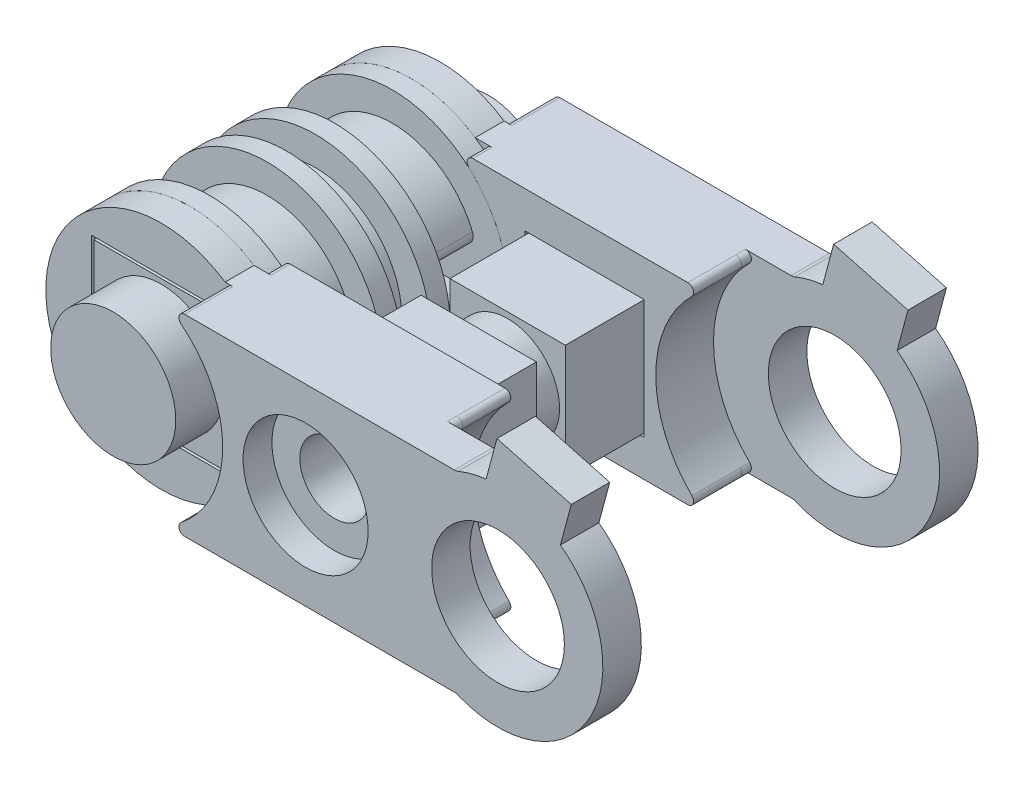
from build123d import *

# Parameters (mm, degrees)
SKETCH_1_R               = 4.5
EXTRUDE_1_DEPTH          = 3
SKETCH_2_R               = 6
EXTRUDE_2_DEPTH          = 1
EXTRUDE_START            = 1.5
SKETCH_3_R               = 4.5
EXTRUDE_3_DEPTH          = 1.5
SKETCH_4_R               = 6.000000000000001
EXTRUDE_4_DEPTH          = 1
EXTRUDE_START_2          = 3
SKETCH_5_R               = 4.5
EXTRUDE_5_DEPTH          = 3
SKETCH_6_R               = 6.000000000000001
EXTRUDE_6_DEPTH          = 1
EXTRUDE_START_3          = 1
SKETCH_7_R               = 6.000000000000001
EXTRUDE_7_DEPTH          = 1
EXTRUDE_10_DEPTH         = 1.5
SKETCH_11_R              = 3.25
EXTRUDE_11_DEPTH         = 2.5
EXTRUDE_12_DEPTH         = 1.5
EXTRUDE_13_DEPTH         = 0.5
FILLET_9_R               = 0.3
SKETCH_14_R              = 3.450000000000003
EXTRUDE_14_DEPTH         = 2
EXTRUDE_15_DEPTH         = 1
SKETCH_16_R              = 1.799999999999999
CUT_EXTRUDE_1_DEPTH      = 33.61828474950821
CUT_EXTRUDE_2_DEPTH      = 2
EXTRUDE_16_DEPTH         = 11.5
SKETCH_19_R              = 1.799999999999999
CUT_EXTRUDE_3_DEPTH      = 30.89903844607716
CUT_EXTRUDE_4_DEPTH      = 0.75
CUT_EXTRUDE_4_DEPTH_BACK = 0.75
SKETCH_20_R              = 2.6999999999999993
SKETCH_21_R              = 3.2500000000000027
CUT_EXTRUDE_5_DEPTH      = 1.5
CUT_EXTRUDE_6_DEPTH      = 1
EXTRUDE_17_DEPTH         = 2
EXTRUDE_18_DEPTH         = 2
SKETCH_25_W              = 3.0000000000000013
SKETCH_25_H              = 2
SKETCH_25_W_2            = 3
CUT_EXTRUDE_7_DEPTH      = 33.95166049436114
FILLET_10_R              = 0.5


with BuildPart() as part:
    # ｽｹｯﾁ1 → ﾎﾞｽ - 押し出し1 (new body)
    with BuildSketch(Plane.XY):
        Circle(SKETCH_1_R)
    extrude(amount=EXTRUDE_1_DEPTH)

    # ｽｹｯﾁ2 → ﾎﾞｽ - 押し出し2 (add)
    with BuildSketch(Plane(origin=(0, 0, 0), x_dir=(-1, 0, 0), z_dir=(0, 0, -1))):
        Circle(SKETCH_2_R)
    extrude(amount=EXTRUDE_2_DEPTH)

    # ｽｹｯﾁ3 → ﾎﾞｽ - 押し出し3 (add)
    with BuildSketch(Plane(origin=(0, 0, -1), x_dir=(-1, 0, 0), z_dir=(0, 0, -1)).offset(EXTRUDE_START)):
        with Locations(Location((0, 0, 0), (0, 0, 180))):
            Circle(SKETCH_3_R)
    extrude(amount=-EXTRUDE_3_DEPTH)

    # ｽｹｯﾁ4 → ﾎﾞｽ - 押し出し4 (add)
    with BuildSketch(Plane(origin=(0, 0, -2.5), x_dir=(-1, 0, 0), z_dir=(0, 0, -1))):
        Circle(SKETCH_4_R)
    extrude(amount=EXTRUDE_4_DEPTH)

    # ｽｹｯﾁ5 → ﾎﾞｽ - 押し出し5 (add)
    with BuildSketch(Plane(origin=(0, 0, -3.5), x_dir=(-1, 0, 0), z_dir=(0, 0, -1)).offset(EXTRUDE_START_2)):
        with Locations(Location((0, 0, 0), (0, 0, 180))):
            Circle(SKETCH_5_R)
    extrude(amount=-EXTRUDE_5_DEPTH)

    # ｽｹｯﾁ6 → ﾎﾞｽ - 押し出し6 (add)
    with BuildSketch(Plane(origin=(0, 0, -6.500000000000001), x_dir=(-1, 0, 0), z_dir=(0, 0, -1))):
        Circle(SKETCH_6_R)
    extrude(amount=EXTRUDE_6_DEPTH)

    # ｽｹｯﾁ7 → ﾎﾞｽ - 押し出し7 (add)
    with BuildSketch(Plane.XY.offset(3).offset(EXTRUDE_START_3)):
        with Locations(Location((0, 0, 0), (0, 0, 180))):
            Circle(SKETCH_7_R)
    extrude(amount=-EXTRUDE_7_DEPTH)

    # ｽｹｯﾁ10 → ﾎﾞｽ - 押し出し10 (add)
    with BuildSketch(Plane.XY.offset(4)):
        Polygon((3.4999999999999996, -3.5), (-3.5000000000000004, -3.500000000000001), (-3.5000000000000004, 3.5000000000000004), (3.4999999999999996, 3.5), align=None)
    extrude_10 = extrude(amount=EXTRUDE_10_DEPTH)

    # ｽｹｯﾁ11 → ﾎﾞｽ - 押し出し11 (add)
    with BuildSketch(Plane.XY.offset(5.5)):
        Circle(SKETCH_11_R)
    extrude_11 = extrude(amount=EXTRUDE_11_DEPTH)

    # ﾐﾗｰ1: ﾎﾞｽ - 押し出し10, ﾎﾞｽ - 押し出し11 across plane
    add(extrude_10.mirror(Plane.XY.offset(-1.7500000000000002)))
    add(extrude_11.mirror(Plane.XY.offset(-1.7500000000000002)))

    # ｽｹｯﾁ25 → ｶｯﾄ - 押し出し7 (cut, through all)
    with BuildSketch(Plane.ZY.offset(4.5)):
        with Locations((-5.000000000000001, 0)):
            Rectangle(SKETCH_25_W, SKETCH_25_H)
        with Locations((1.5, 0)):
            Rectangle(SKETCH_25_W_2, SKETCH_25_H)
    extrude(amount=-CUT_EXTRUDE_7_DEPTH, mode=Mode.SUBTRACT)

    # ﾌｨﾚｯﾄ10
    fillet_10_edges = [part.edges().sort_by_distance(p)[0] for p in [
        (-4.387482193696061, 1, -5),
        (4.387482193696061, 1, -5),
        (4.387482193696061, -1, -5),
        (-4.387482193696061, -1, -5),
        (4.387482193696061, 1, 1.5),
        (-4.387482193696061, 1, 1.5),
        (-4.387482193696061, -1, 1.5),
        (4.387482193696061, -1, 1.5),
    ]]
    fillet(fillet_10_edges, radius=FILLET_10_R)


with BuildPart() as body_2:
    # ｽｹｯﾁ12 → ﾎﾞｽ - 押し出し12 (new body)
    with BuildSketch(Plane.XY.offset(4)):
        with BuildLine():
            Line((3.3166247903554016, 5), (16.167246420652642, 5))
            ThreePointArc((16.167246420652642, 5), (13.700000000000001, 3.57e-15), (16.16724642065264, -5))
            Line((16.16724642065264, -5), (3.3166247903553985, -5.000000000000003))
            ThreePointArc((3.3166247903553985, -5.000000000000003), (-6.000000000000001, 7.3e-16), (3.3166247903554016, 5))
        make_face()
        Polygon((3.6399999999999997, -3.64), (3.6399999999999997, 3.64), (-3.6400000000000006, 3.6400000000000006), (-3.6400000000000006, -3.640000000000001), align=None, mode=Mode.SUBTRACT)
    extrude(amount=EXTRUDE_12_DEPTH)

    # ｽｹｯﾁ13 → ﾎﾞｽ - 押し出し13 (add)
    with BuildSketch(Plane.XY.offset(5.5)):
        with BuildLine():
            Line((15.366426864718767, 5.000000000000001), (3.71350238992787, 4.999999999999999))
            ThreePointArc((3.71350238992787, 4.999999999999999), (3.4301142319534543, 4.798443648448575), (3.5275172952737197, 4.464607679465777))
            ThreePointArc((3.5275172952737197, 4.464607679465777), (5.69, 3.16e-15), (3.527517295273725, -4.464607679465773))
            ThreePointArc((3.527517295273725, -4.464607679465773), (3.4301142319534588, -4.798443648448569), (3.713502389927875, -4.9999999999999964))
            Line((3.713502389927875, -4.9999999999999964), (15.366426864718758, -4.999999999999996))
            ThreePointArc((15.366426864718758, -4.999999999999996), (15.643997494550977, -4.813818036595895), (15.57704382541336, -4.486363636363631))
            ThreePointArc((15.57704382541336, -4.486363636363631), (13.7, 6.37e-15), (15.577043825413366, 4.486363636363639))
            ThreePointArc((15.577043825413366, 4.486363636363639), (15.643997494550984, 4.813818036595901), (15.366426864718767, 5.000000000000001))
        make_face()
    extrude(amount=EXTRUDE_13_DEPTH)

    # ﾌｨﾚｯﾄ9
    fillet_9_edges = [body_2.edges().sort_by_distance(p)[0] for p in [
        (16.16724642065264, -5.000000000000001, 4.75),
        (16.167246420652642, 5, 4.75),
    ]]
    fillet(fillet_9_edges, radius=FILLET_9_R)

    # ｽｹｯﾁ14 → ﾎﾞｽ - 押し出し14 (add)
    with BuildSketch(Plane.XY.offset(6)):
        with BuildLine():
            Line((3.71350238992787, 5), (17.73008810743677, 5))
            ThreePointArc((17.73008810743677, 5), (17.827318665969592, 5.00954488636839), (17.920837005971492, 5.03781512605042))
            ThreePointArc((17.920837005971492, 5.03781512605042), (25.45, 2.42e-15), (17.920837005971496, -5.037815126050422))
            ThreePointArc((17.920837005971496, -5.037815126050422), (17.827318665969596, -5.009544886368393), (17.730088107436774, -5.000000000000003))
            Line((17.730088107436774, -5.000000000000003), (3.713502389927875, -5.000000000000003))
            ThreePointArc((3.713502389927875, -5.000000000000003), (3.430114231953458, -4.79844364844857), (3.5275172952737246, -4.4646076794657725))
            ThreePointArc((3.5275172952737246, -4.4646076794657725), (5.69, 3.16e-15), (3.52751729527372, 4.464607679465777))
            ThreePointArc((3.52751729527372, 4.464607679465777), (3.4301142319534534, 4.798443648448575), (3.71350238992787, 5))
        make_face()
        with Locations((20, 0)):
            Circle(SKETCH_14_R, mode=Mode.SUBTRACT)
    extrude(amount=EXTRUDE_14_DEPTH)

    # ｽｹｯﾁ15 → ﾎﾞｽ - 押し出し15 (add)
    with BuildSketch(Plane(origin=(0, 0, 4), x_dir=(-1, 0, 0), z_dir=(0, 0, -1))):
        with BuildLine():
            Line((-15.366426864718765, 5), (-4.195235392680607, 5.000000000000001))
            ThreePointArc((-4.195235392680607, 5.000000000000001), (-3.9149294373899135, 4.806904496764971), (-3.9954622787434353, 4.476190476190477))
            ThreePointArc((-3.9954622787434353, 4.476190476190477), (-6.000000000000001, 7.3e-16), (-3.9954622787434353, -4.476190476190477))
            ThreePointArc((-3.9954622787434353, -4.476190476190477), (-3.9149294373899135, -4.806904496764971), (-4.195235392680607, -5.000000000000001))
            Line((-4.195235392680607, -5.000000000000001), (-15.366426864718763, -5))
            ThreePointArc((-15.366426864718763, -5), (-15.643997494550984, -4.813818036595896), (-15.577043825413359, -4.48636363636363))
            ThreePointArc((-15.577043825413359, -4.48636363636363), (-13.700000000000001, 4.2e-15), (-15.577043825413364, 4.486363636363636))
            ThreePointArc((-15.577043825413364, 4.486363636363636), (-15.643997494550984, 4.813818036595898), (-15.366426864718765, 5))
        make_face()
    extrude(amount=EXTRUDE_15_DEPTH)


with BuildPart() as body_3:
    # ﾐﾗｰ2: mirrored copy
    add(body_2.part.mirror(Plane.XY.offset(-1.7500000000000002)))


with BuildPart() as cut_extrude_1_tool:
    # ｽｹｯﾁ16 → ｶｯﾄ - 押し出し1 (new, through all)
    with BuildSketch(Plane.XY.offset(8)):
        with Locations((10, 0)):
            Circle(SKETCH_16_R)
    extrude(amount=-CUT_EXTRUDE_1_DEPTH)


with BuildPart() as body_2_1:
    add(body_2.part)

    # ｶｯﾄ - 押し出し1: cut by cut_extrude_1_tool
    add(cut_extrude_1_tool.part, mode=Mode.SUBTRACT)

    # ｽｹｯﾁ18 → ﾎﾞｽ - 押し出し16 (add)
    with BuildSketch(Plane(origin=(0, 0, 3), x_dir=(-1, 0, 0), z_dir=(0, 0, -1))):
        Polygon((-7.000000000000002, 2.9999999999999996), (-13.000000000000002, 2.9999999999999987), (-13.000000000000002, -2.9999999999999996), (-7.000000000000002, -2.999999999999999), align=None)
    extrude(amount=EXTRUDE_16_DEPTH)

    # ｽｹｯﾁ19 → ｶｯﾄ - 押し出し3 (cut, through all)
    with BuildSketch(Plane.XY.offset(3)):
        with Locations((10, 0)):
            Circle(SKETCH_19_R)
    extrude(amount=-CUT_EXTRUDE_3_DEPTH, mode=Mode.SUBTRACT)

    # ｽｹｯﾁ20 → ｶｯﾄ - 押し出し4 (cut, two sides: drawn at the far end of the back side and taken through both)
    with BuildSketch(Plane.XY.offset(-1.7500000000000002).offset(-CUT_EXTRUDE_4_DEPTH_BACK)):
        Polygon((13.000000000000002, 2.9999999999999987), (7.000000000000002, 2.9999999999999996), (7.000000000000002, -2.999999999999999), (13.000000000000002, -2.9999999999999996), align=None)
        with Locations((10, 0)):
            Circle(SKETCH_20_R, mode=Mode.SUBTRACT)
    extrude(amount=CUT_EXTRUDE_4_DEPTH + CUT_EXTRUDE_4_DEPTH_BACK, mode=Mode.SUBTRACT)

    # ｽｹｯﾁ21 → ｶｯﾄ - 押し出し5 (cut)
    with BuildSketch(Plane.XY.offset(8)):
        with Locations((10, 0)):
            Circle(SKETCH_21_R)
    extrude(amount=-CUT_EXTRUDE_5_DEPTH, mode=Mode.SUBTRACT)

    # ｽｹｯﾁ23 → ﾎﾞｽ - 押し出し17 (add)
    with BuildSketch(Plane.XY.offset(8)):
        Polygon((19.01283786204607, 4.043267356160141), (22.87654116720234, 3.007991175750056), (23.808289729571417, 6.485324150390701), (19.944586424415146, 7.520600330800787), align=None)
    extrude(amount=-EXTRUDE_17_DEPTH)


with BuildPart() as body_3_1:
    add(body_3.part)

    # ｶｯﾄ - 押し出し1: cut by cut_extrude_1_tool
    add(cut_extrude_1_tool.part, mode=Mode.SUBTRACT)

    # ｽｹｯﾁ17 → ｶｯﾄ - 押し出し2 (cut)
    with BuildSketch(Plane.XY.offset(-6.500000000000001)):
        Polygon((13.100000000000001, -3.0999999999999996), (6.900000000000001, -3.1000000000000005), (6.900000000000001, 3.0999999999999996), (13.100000000000001, 3.1000000000000005), align=None)
    extrude(amount=-CUT_EXTRUDE_2_DEPTH, mode=Mode.SUBTRACT)

    # ｽｹｯﾁ22 → ｶｯﾄ - 押し出し6 (cut)
    with BuildSketch(Plane(origin=(0, 0, -11.5), x_dir=(-1, 0, 0), z_dir=(0, 0, -1))):
        Polygon((-11.674315780649914, 2.8999999999999995), (-13.348631561299829, 1e-17), (-11.674315780649913, -2.900000000000001), (-8.325684219350087, -2.9000000000000004), (-6.651368438700171, -8.7e-16), (-8.325684219350087, 2.9), align=None)
    extrude(amount=-CUT_EXTRUDE_6_DEPTH, mode=Mode.SUBTRACT)

    # ｽｹｯﾁ24 → ﾎﾞｽ - 押し出し18 (add)
    with BuildSketch(Plane(origin=(0, 0, -11.5), x_dir=(-1, 0, 0), z_dir=(0, 0, -1))):
        Polygon((-22.87654116720234, 3.007991175750056), (-19.01283786204607, 4.043267356160141), (-19.944586424415146, 7.520600330800787), (-23.808289729571417, 6.485324150390701), align=None)
    extrude(amount=-EXTRUDE_18_DEPTH)


solid = Compound([part.part, body_2_1.part, body_3_1.part])
